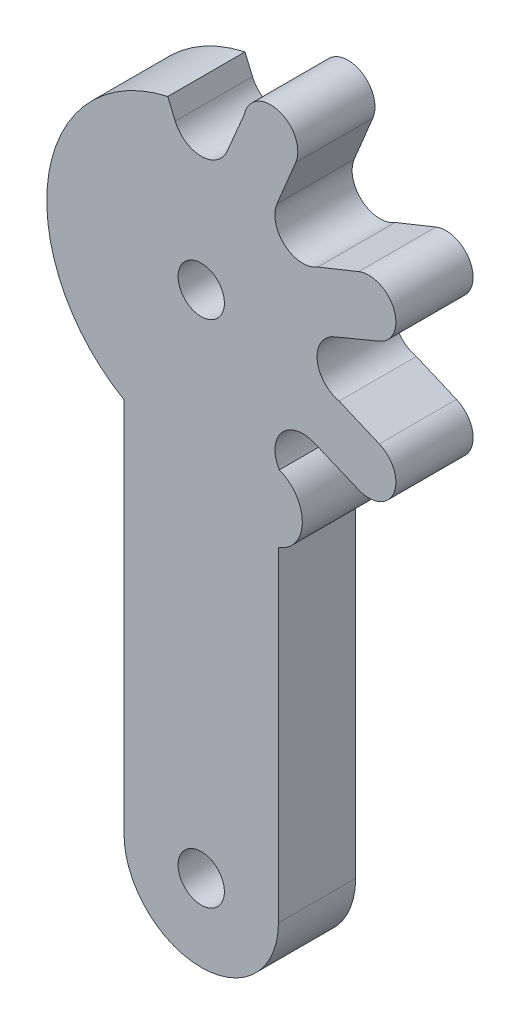
from build123d import *

# Parameters (mm, degrees)
SKETCH2_R           = 1.5
BOSS_EXTRUDE1_DEPTH = 5


with BuildPart() as part:
    # Sketch2 → Boss-Extrude1 (new body)
    with BuildSketch(Plane.XY):
        with BuildLine():
            Line((2.786749194, 11.219281361), (1.679332735, 8.620125122))
            ThreePointArc((1.679332735, 8.620125122), (0, 7.492843349), (-1.679332735, 8.620125122))
            Line((-1.679332735, 8.620125122), (-2.166097038, 9.762582836))
            ThreePointArc((-2.166097038, 9.762582836), (-9.883747584, 1.52037288), (-5, -8.660254038))
            Line((-5, -8.660254038), (-5, -33))
            ThreePointArc((-5, -33), (0, -38), (5, -32.999999999))
            Line((5, -32.999999999), (4.999812723, -11.943549515))
            ThreePointArc((4.999812723, -11.943549515), (6.546655646, -9.774570585), (5.060672488, -7.563451711))
            ThreePointArc((5.060672488, -7.563451711), (5.196669714, -5.419737645), (7.282816493, -4.907881363))
            Line((7.282816493, -4.907881363), (10.186929901, -6.110804524))
            ThreePointArc((10.186929901, -6.110804524), (12.473305355, -5.163446511), (11.525947342, -2.877071058))
            Line((11.525947342, -2.877071058), (8.926791103, -1.769654599))
            ThreePointArc((8.926791103, -1.769654599), (7.507129847, -0.157755799), (8.620125937, 1.679333073))
            Line((8.620125937, 1.679333073), (11.524239345, 2.882256233))
            ThreePointArc((11.524239345, 2.882256233), (12.471253953, 5.168928764), (10.18447198, 6.11567907))
            Line((10.18447198, 6.11567907), (7.56352929, 5.060859756))
            ThreePointArc((7.56352929, 5.060859756), (5.419892956, 5.196791944), (4.907881363, 7.282816493))
            Line((4.907881363, 7.282816493), (6.110804524, 10.186929901))
            ThreePointArc((6.110804524, 10.186929901), (5.022287729, 12.549745986), (2.786749194, 11.219281361))
        make_face()
        with Locations((0, -33)):
            Circle(SKETCH2_R, mode=Mode.SUBTRACT)
        Circle(SKETCH2_R, mode=Mode.SUBTRACT)
    extrude(amount=BOSS_EXTRUDE1_DEPTH)


solid = part.part
